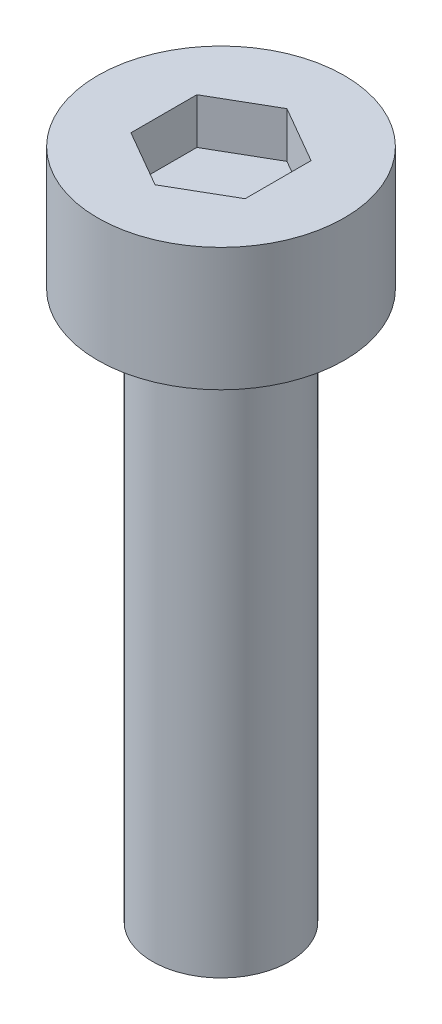
from build123d import *

# Parameters (mm, degrees)
SKETCH1_R           = 2.7
BOSS_EXTRUDE1_DEPTH = 2.7
CUT_EXTRUDE1_DEPTH  = 1
SKETCH3_R           = 1.5
BOSS_EXTRUDE2_DEPTH = 12


with BuildPart() as part:
    # Sketch1 → Boss-Extrude1 (new body)
    with BuildSketch(Plane(origin=(0, 0, 0), x_dir=(1, 0, 0), z_dir=(0, 1, 0))):
        Circle(SKETCH1_R)
    extrude(amount=BOSS_EXTRUDE1_DEPTH)

    # Sketch2 → Cut-Extrude1 (cut)
    with BuildSketch(Plane(origin=(0, 2.7, 0), x_dir=(1, 0, 0), z_dir=(0, 1, 0))):
        Polygon((0, 1.443375673), (-1.25, 0.721687836), (-1.25, -0.721687836), (0, -1.443375673), (1.25, -0.721687836), (1.25, 0.721687836), align=None)
    extrude(amount=-CUT_EXTRUDE1_DEPTH, mode=Mode.SUBTRACT)

    # Sketch3 → Boss-Extrude2 (add)
    with BuildSketch(Plane.XZ):
        Circle(SKETCH3_R)
    extrude(amount=BOSS_EXTRUDE2_DEPTH)


solid = part.part
